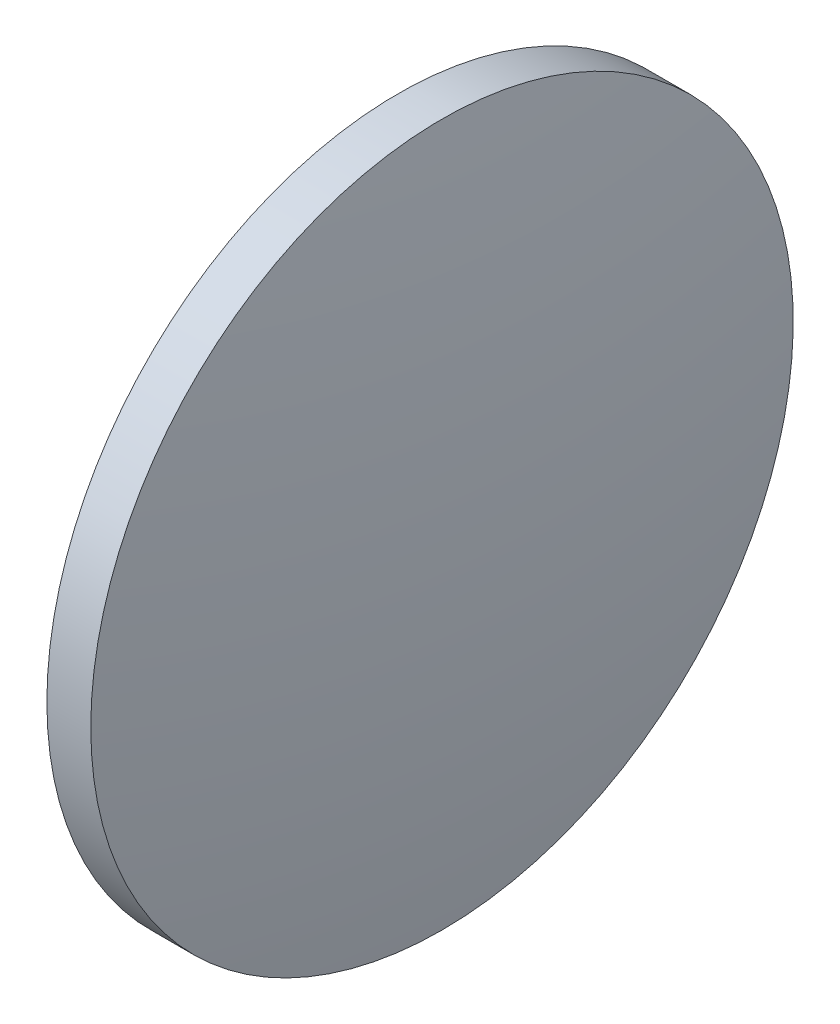
from build123d import *


with BuildPart() as part:
    # 草图1 → 旋转1 (revolve)
    with BuildSketch(Plane.XY, mode=Mode.PRIVATE) as revolve_1_sk:
        with BuildLine():
            Line((449.947960124, 48.340040201), (449.947960124, 68.340040201))
            Line((449.947960124, 68.340040201), (452.447960124, 68.340040201))
            ThreePointArc((452.447960124, 68.340040201), (453.617368732, 58.370414072), (454.007960124, 48.340040201))
            Line((454.007960124, 48.340040201), (449.947960124, 48.340040201))
        make_face()
    revolve(revolve_1_sk.sketch.rotate(Axis((445.253416944, 48.340040201, 0), (1, 0, 0)), 180), axis=Axis((445.253416944, 48.340040201, 0), (1, 0, 0)))  # turned: the seam where the file's is


solid = part.part
